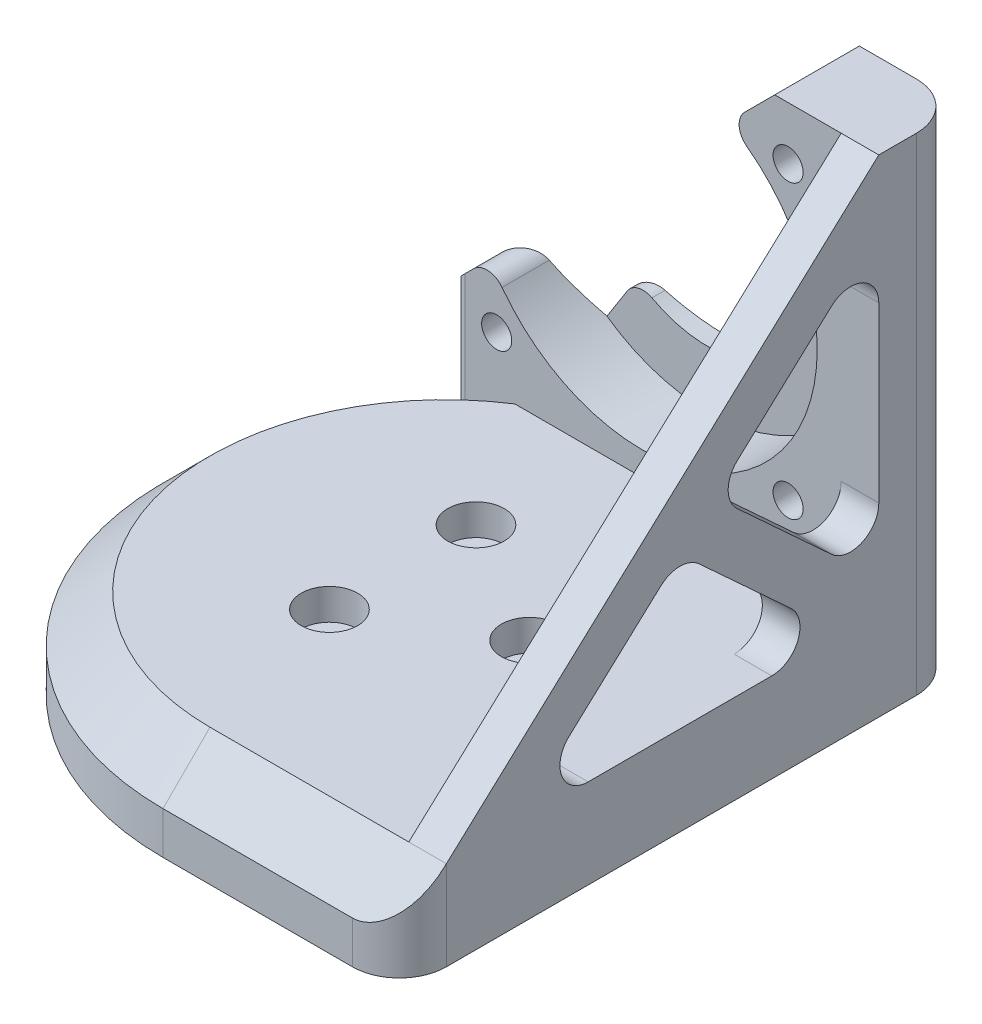
from build123d import *

# Parameters (mm, degrees)
SKETCH_1_R               = 12.4
SKETCH_1_R_2             = 1.5999999999999976
SKETCH_1_R_3             = 1.5999999999999506
SKETCH_1_R_4             = 1.6
EXTRUDE_1_DEPTH          = 20
EXTRUDE_START            = -9.5
SKETCH_2_R               = 12.4
EXTRUDE_2_DEPTH          = 9.5
SKETCH_4_R               = 2.999999999999999
SKETCH_4_R_2             = 3.0000000000000004
SKETCH_4_R_3             = 3
CUT_EXTRUDE_1_DEPTH      = 3.3
SKETCH_5_R               = 1.6
SKETCH_5_R_2             = 1.5999999999999956
SKETCH_5_R_3             = 1.6000000000000036
EXTRUDE_3_DEPTH          = 9
EXTRUDE_4_DEPTH          = 4
CUT_EXTRUDE_2_DEPTH      = 60.910683521388734
CUT_EXTRUDE_3_DEPTH      = 92.54938567789519
CUT_EXTRUDE_3_DEPTH_BACK = 3.3
SKETCH_8_R               = 2.9999999999999982
SKETCH_8_R_2             = 2.9999999999999973
CHAMFER_1_SIZE           = 5
EXTRUDE_7_REACH          = 87.92
SKETCH_9_R               = 18.6
CUT_EXTRUDE_7_DEPTH      = 67.95700121719909
EXTRUDE_START_2          = -5.7
SKETCH_18_R              = 2.999999999999999
SKETCH_18_R_2            = 1.6000000000000036
EXTRUDE_8_DEPTH          = 5.7
SKETCH_19_R              = 2.999999999999999
CUT_EXTRUDE_8_DEPTH      = 90.42136219796699
SKETCH_20_R              = 18.6
CUT_EXTRUDE_9_DEPTH      = 7
CUT_EXTRUDE_10_DEPTH     = 7
FILLET_2_R               = 2
SKETCH_22_R              = 12.600000000000001
CUT_EXTRUDE_11_DEPTH     = 7
FILLET_3_R               = 2
CUT_EXTRUDE_12_DEPTH     = 87.00937458341387
FILLET_4_R               = 3
CUT_EXTRUDE_13_DEPTH     = 60.91068362153782
FILLET_5_R               = 1
FILLET_6_R               = 5
CHAMFER_2_SIZE           = 1


with BuildPart() as part:
    # 草图1 → 凸台-拉伸1 (new body)
    with BuildSketch(Plane(origin=(0, 0, 0), x_dir=(1, 0, 0), z_dir=(0, 1, 0))):
        with Locations(Location((0, 0, 0), (0, 0, 270))):
            Circle(SKETCH_1_R)
        with Locations(Location((9.000000000000002, 2.1e-15, 0), (0, 0, 270))):
            Circle(SKETCH_1_R_2, mode=Mode.SUBTRACT)
        with Locations(Location((-4.500000000000038, -7.794228634059926, 0), (0, 0, 270))):
            Circle(SKETCH_1_R_3, mode=Mode.SUBTRACT)
        with Locations(Location((-4.499999999999964, 7.794228634060018, 0), (0, 0, 270))):
            Circle(SKETCH_1_R_4, mode=Mode.SUBTRACT)
    extrude(amount=EXTRUDE_1_DEPTH)

    # 草图2 → 凸台-拉伸2 (add)
    with BuildSketch(Plane(origin=(0, 20, 0), x_dir=(1, 0, 0), z_dir=(0, 1, 0)).offset(EXTRUDE_START)):
        with BuildLine():
            Line((0, 30), (25.15, 30))
            Line((25.15, 30), (25.15, -30))
            Line((25.15, -30), (0, -30))
            ThreePointArc((0, -30), (-30, 3.67e-15), (0, 30))
        make_face()
        with Locations(Location((0, 0, 0), (0, 0, 270))):
            Circle(SKETCH_2_R, mode=Mode.SUBTRACT)
    extrude(amount=EXTRUDE_2_DEPTH)

    # 草图4 → 切除-拉伸1 (cut)
    with BuildSketch(Plane(origin=(0, 20, 0), x_dir=(1, 0, 0), z_dir=(0, 1, 0))):
        with Locations(Location((9.000000000000002, 2.1e-15, 0), (0, 0, 270))):
            Circle(SKETCH_4_R)
        with Locations(Location((-4.499999999999964, 7.794228634060018, 0), (0, 0, 270))):
            Circle(SKETCH_4_R_2)
        with Locations(Location((-4.500000000000038, -7.794228634059926, 0), (0, 0, 270))):
            Circle(SKETCH_4_R_3)
    extrude(amount=-CUT_EXTRUDE_1_DEPTH, mode=Mode.SUBTRACT)

    # 草图5 → 凸台-拉伸3 (add)
    with BuildSketch(Plane(origin=(0, 0, -30), x_dir=(-1, 0, -1.7e-16), z_dir=(1.7e-16, 0, -1))):
        Polygon((-25.15, 20), (-25.15, 62.3), (-14.078932188134525, 62.3), (28.22106781186546, 20), align=None)
        with Locations((-15.500000000000005, 25.649999999999995)):
            Circle(SKETCH_5_R, mode=Mode.SUBTRACT)
        with Locations((-15.499999999999998, 56.64999999999999)):
            Circle(SKETCH_5_R_2, mode=Mode.SUBTRACT)
        with Locations((15.499999999999995, 25.64999999999999)):
            Circle(SKETCH_5_R_3, mode=Mode.SUBTRACT)
    extrude(amount=-EXTRUDE_3_DEPTH)

    # 草图6 → 凸台-拉伸4 (add)
    with BuildSketch(Plane(origin=(25.15, 0, 0), x_dir=(0, 0, -1), z_dir=(1, 0, 0))):
        Polygon((-24.999999999999996, 19.999999999999996), (20.999999999999996, 62.3), (20.999999999999996, 20), align=None)
    extrude(amount=-EXTRUDE_4_DEPTH)

    # 草图7 → 切除-拉伸2 (cut, through all)
    with BuildSketch(Plane.XZ.offset(-20)):
        with BuildLine():
            Line((-28.22106781186546, -30.000000000000004), (3.9e-15, -30))
            ThreePointArc((3.9e-15, -30), (-11.618950038622252, -27.65863337187866), (-21.42428528562855, -21))
            Line((-21.42428528562855, -21), (-28.22106781186546, -21.000000000000004))
            Line((-28.22106781186546, -21.000000000000004), (-28.22106781186546, -30.000000000000004))
        make_face()
    extrude(amount=-CUT_EXTRUDE_2_DEPTH, mode=Mode.SUBTRACT)

    # 草图8 → 切除-拉伸3 (cut, two sides: drawn at the far end of the back side and taken through both)
    with BuildSketch(Plane(origin=(0, 0, -30), x_dir=(-1, 0, -1.7e-16), z_dir=(1.7e-16, 0, -1)).offset(-CUT_EXTRUDE_3_DEPTH_BACK)):
        with Locations(Location((-15.499999999999998, 56.64999999999999, 0), (0, 0, 180))):
            Circle(SKETCH_8_R)
        with Locations(Location((-15.500000000000005, 25.649999999999995, 0), (0, 0, 180))):
            Circle(SKETCH_8_R_2)
    extrude(amount=CUT_EXTRUDE_3_DEPTH + CUT_EXTRUDE_3_DEPTH_BACK, mode=Mode.SUBTRACT)

    # 倒角1
    chamfer_1_edges = [part.edges().sort_by_distance(p)[0] for p in [
        (12.575, 20, 30),
        (-27.65863337187878, 20, 11.618950038621964),
    ]]
    chamfer(chamfer_1_edges, length=CHAMFER_1_SIZE)

    # 凸台-拉伸7: up to this face of the body (flat: up to its plane)
    extrude_7_end = Plane(part.part.faces().sort_by_distance((13.111797909, 34.333599445, -30))[0])
    # 草图9 → 凸台-拉伸7 (add, up to the picked face)
    with BuildSketch(Plane.XY.offset(-20.999999999999996), mode=Mode.PRIVATE) as extrude_7_sk1:
        with Locations((-1.73e-15, 41.14999999999999)):
            Circle(SKETCH_9_R)
    extrude_7_tool1 = split(extrude(extrude_7_sk1.sketch, amount=-EXTRUDE_7_REACH, mode=Mode.PRIVATE), bisect_by=extrude_7_end, keep=Keep.BOTH, mode=Mode.PRIVATE)
    add(extrude_7_tool1.solids().sort_by(Axis((0, 41.15, -21), (0, 0, -1)))[0])

    # 草图17 → 切除-拉伸7 (cut, through all)
    with BuildSketch(Plane.XZ.offset(-10.5)):
        with BuildLine():
            Line((0, -30), (-18.6, -30))
            Line((-18.6, -30), (-18.6, -23.538054295119636))
            ThreePointArc((-18.6, -23.538054295119636), (-9.845262087583318, -28.338504096490247), (0, -30))
        make_face()
    extrude(amount=-CUT_EXTRUDE_7_DEPTH, mode=Mode.SUBTRACT)

    # 草图18 → 凸台-拉伸8 (add)
    with BuildSketch(Plane.XY.offset(-20.999999999999996).offset(EXTRUDE_START_2)):
        with Locations((-15.5, 25.64999999999999)):
            Circle(SKETCH_18_R)
        with Locations(Location((-15.5, 25.64999999999999, 0), (0, 0, 180))):
            Circle(SKETCH_18_R_2, mode=Mode.SUBTRACT)
    extrude(amount=EXTRUDE_8_DEPTH)

    # 草图19 → 切除-拉伸8 (cut, through all)
    with BuildSketch(Plane(origin=(4.63e-15, 0, -26.7), x_dir=(-1, 0, -1.7e-16), z_dir=(1.7e-16, 0, -1))):
        with Locations((15.500000000000002, 25.64999999999999)):
            Circle(SKETCH_19_R)
    extrude(amount=CUT_EXTRUDE_8_DEPTH, mode=Mode.SUBTRACT)

    # 草图20 → 切除-拉伸9 (cut)
    with BuildSketch(Plane.XY.offset(-20.999999999999996)):
        with Locations((-1.73e-15, 41.14999999999999)):
            Circle(SKETCH_20_R)
    extrude(amount=-CUT_EXTRUDE_9_DEPTH, mode=Mode.SUBTRACT)

    # 草图21 → 切除-拉伸10 (cut)
    with BuildSketch(Plane.XY.offset(-27.999999999999996)):
        with BuildLine():
            Line((9.132536191757762, 57.353604003623225), (-10.770329614269013, 25.985567930186104))
            Line((-10.770329614269013, 25.985567930186104), (-10.770329614269013, 56.31443206981388))
            ThreePointArc((-10.770329614269013, 56.31443206981388), (-0.9698254485780136, 59.72469888313914), (9.132536191757762, 57.353604003623225))
        make_face()
    extrude(amount=-CUT_EXTRUDE_10_DEPTH, mode=Mode.SUBTRACT)

    # 圆角2
    fillet_2_edges = [part.edges().sort_by_distance(p)[0] for p in [
        (9.132536191757753, 57.353604003623225, -24.499999999999996),
        (-16.203604003623234, 32.01746380824223, -23.123818927861777),
    ]]
    fillet(fillet_2_edges, radius=FILLET_2_R)

    # 草图22 → 切除-拉伸11 (cut)
    with BuildSketch(Plane.XY.offset(-27.999999999999996)):
        with Locations((1e-15, 41.14999999999999)):
            Circle(SKETCH_22_R)
    extrude(amount=-CUT_EXTRUDE_11_DEPTH, mode=Mode.SUBTRACT)

    # 圆角3
    fillet_3_edges = [part.edges().sort_by_distance(p)[0] for p in [
        (5.91155300792769, 52.27715332124353, -29),
        (-7.549346430438945, 31.062018612565794, -28.51729458674393),
    ]]
    fillet(fillet_3_edges, radius=FILLET_3_R)

    # 草图23 → 切除-拉伸12 (cut, through all)
    with BuildSketch(Plane.ZY.offset(-21.15)):
        Polygon((-3.5400992489435197, 39.45183914325861), (-21.000000000000007, 55.50735657303446), (-21.000000000000004, 23.396321713482756), align=None)
        Polygon((17.613201001408648, 20), (0.1533002503521459, 36.05551742977586), (-17.306600500704334, 20), align=None)
    extrude(amount=-CUT_EXTRUDE_12_DEPTH, mode=Mode.SUBTRACT)

    # 圆角4
    fillet_4_edges = [part.edges().sort_by_distance(p)[0] for p in [
        (23.15, 20, -17.306600500704334),
        (23.15, 36.05551742977586, 0.15330025035214767),
        (23.15, 20, 17.613201001408648),
        (23.15, 23.396321713482756, -21.000000000000004),
        (23.15, 55.50735657303446, -21.000000000000007),
        (23.15, 39.45183914325861, -3.540099248943516),
    ]]
    fillet(fillet_4_edges, radius=FILLET_4_R)

    # 草图24 → 切除-拉伸13 (cut, through all)
    with BuildSketch(Plane(origin=(0, 20, 0), x_dir=(1, 0, 0), z_dir=(0, 1, 0))):
        with BuildLine():
            Line((25.15, -24.999999999999996), (25.15, -30))
            Line((25.15, -30), (20.15, -30))
            ThreePointArc((20.15, -30), (23.685533905932736, -28.535533905932734), (25.15, -24.999999999999996))
        make_face()
    extrude(amount=-CUT_EXTRUDE_13_DEPTH, mode=Mode.SUBTRACT)

    # 圆角5
    fillet_5_edges = [part.edges().sort_by_distance(p)[0] for p in [
        (-21.42428528562855, 20.898391263118448, -21.000000000000007),
    ]]
    fillet(fillet_5_edges, radius=FILLET_5_R)

    # 圆角6
    fillet_6_edges = [part.edges().sort_by_distance(p)[0] for p in [
        (25.15, 36.4, -29.999999999999996),
    ]]
    fillet(fillet_6_edges, radius=FILLET_6_R)

    # 倒角2
    chamfer_2_edges = [part.edges().sort_by_distance(p)[0] for p in [
        (3.8e-15, 0, -12.4),
    ]]
    chamfer(chamfer_2_edges, length=CHAMFER_2_SIZE)


solid = part.part
